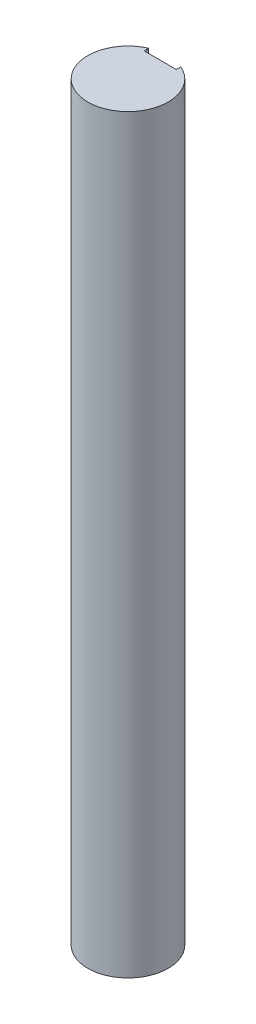
from build123d import *

# Parameters (mm, degrees)
SKETCH1_R           = 3.75
BOSS_EXTRUDE1_DEPTH = 70
CUT_EXTRUDE1_DEPTH  = 71


with BuildPart() as part:
    # Sketch1 → Boss-Extrude1 (new body)
    with BuildSketch(Plane(origin=(0, 0, 0), x_dir=(1, 0, 0), z_dir=(0, 1, 0))):
        Circle(SKETCH1_R)
    extrude(amount=BOSS_EXTRUDE1_DEPTH)

    # Sketch2 → Cut-Extrude1 (cut, through all)
    with BuildSketch(Plane(origin=(0, 70, 0), x_dir=(1, 0, 0), z_dir=(0, 1, 0))):
        Polygon((0, 3.010531791), (-1.5, 3.010531791), (-1.5, 3.75), (1.5, 3.75), (1.5, 3.010531791), align=None)
    extrude(amount=-CUT_EXTRUDE1_DEPTH, mode=Mode.SUBTRACT)


solid = part.part
